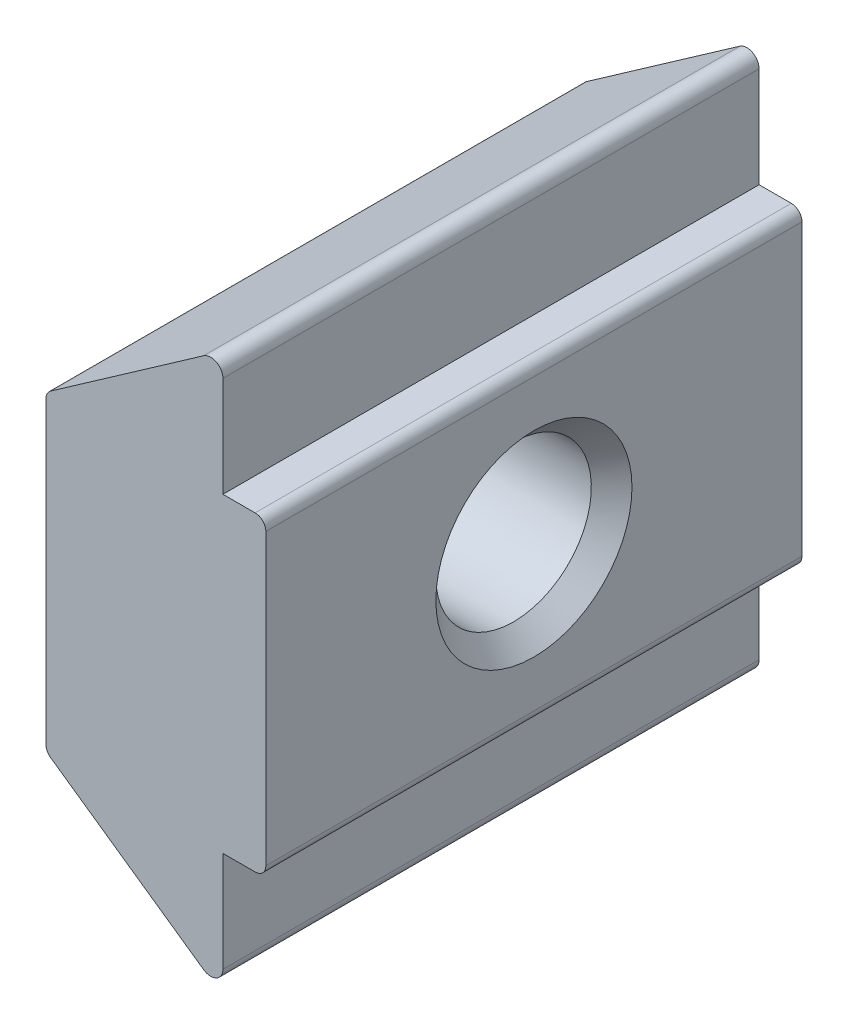
from build123d import *

# Parameters (mm, degrees)
BOSS_EXTRUDE1_DEPTH           = 10
SKETCH2_W                     = 10
SKETCH2_H                     = 5.8
BOSS_EXTRUDE2_DEPTH           = 0.8
TAP_DRILL_FOR_M3_5X0_6_TAP1_D = 2.9
CHAMFER1_SIZE                 = 0.379
FILLET1_R                     = 0.2


with BuildPart() as part:
    # Sketch1 → Boss-Extrude1 (new body)
    with BuildSketch(Plane.XY.offset(5)):
        with BuildLine():
            Line((-0.8, -4.771898466), (-0.8, 4.771898466))
            ThreePointArc((-0.8, 4.771898466), (-0.922761052, 4.974218302), (-1.158906761, 4.958765267))
            Line((-1.158906761, 4.958765267), (-4.1, 2.9))
            Line((-4.1, 2.9), (-4.1, -2.9))
            Line((-4.1, -2.9), (-1.158906761, -4.958765267))
            ThreePointArc((-1.158906761, -4.958765267), (-0.922761052, -4.974218302), (-0.8, -4.771898466))
        make_face()
    extrude(amount=-BOSS_EXTRUDE1_DEPTH)

    # Sketch2 → Boss-Extrude2 (add)
    with BuildSketch(Plane(origin=(-0.8, 0, 0), x_dir=(0, 0, -1), z_dir=(1, 0, 0))):
        Rectangle(SKETCH2_W, SKETCH2_H)
    extrude(amount=BOSS_EXTRUDE2_DEPTH)

    # Tap Drill for M3.5x0.6 Tap1 (through all)
    with Locations(Plane(origin=(0, 0, 0), x_dir=(0, 0, -1), z_dir=(1, 0, 0))):
        with Locations((0, 0)):
            Hole(TAP_DRILL_FOR_M3_5X0_6_TAP1_D / 2)

    # Chamfer1
    chamfer1_edges = [part.edges().sort_by_distance(p)[0] for p in [
        (0, 0, -1.45),
        (-4.1, 0, -1.45),
    ]]
    chamfer(chamfer1_edges, length=CHAMFER1_SIZE)

    # Fillet1
    fillet1_edges = [part.edges().sort_by_distance(p)[0] for p in [
        (-4.1, -2.9, 0),
        (-4.1, 2.9, 0),
        (0, 2.9, 0),
        (0, -2.9, 0),
    ]]
    fillet(fillet1_edges, radius=FILLET1_R)


solid = part.part
